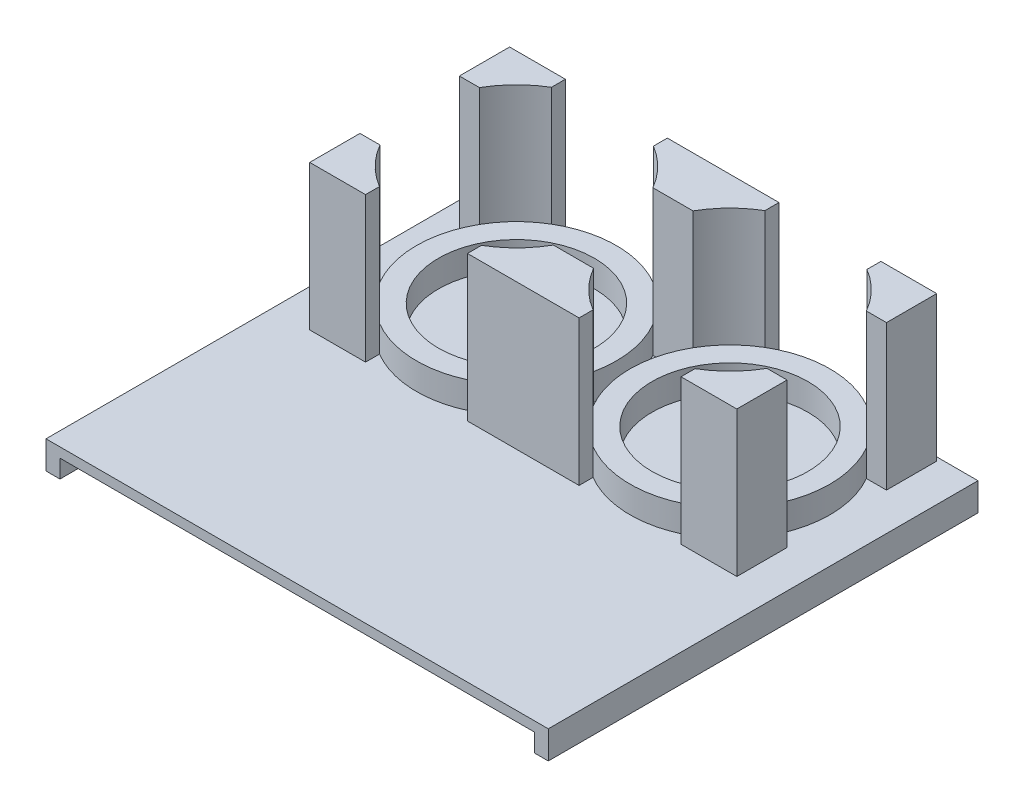
from build123d import *

# Parameters (mm, degrees)
SKETCH1_W           = 85
SKETCH1_H           = 77
BOSS_EXTRUDE1_DEPTH = 1.75
SKETCH3_R           = 17.907
SKETCH3_R_2         = 13.97
BOSS_EXTRUDE3_DEPTH = 4.7625
BOSS_EXTRUDE7_DEPTH = 26
SKETCH6_W           = 77
SKETCH6_H           = 5
BOSS_EXTRUDE8_DEPTH = 2.5


with BuildPart() as part:
    # Sketch1 → Boss-Extrude1 (new body)
    with BuildSketch(Plane(origin=(0, 0, 0), x_dir=(1, 0, 0), z_dir=(0, 1, 0))):
        Rectangle(SKETCH1_W, SKETCH1_H)
    extrude(amount=BOSS_EXTRUDE1_DEPTH)

    # Sketch3 → Boss-Extrude3 (add)
    with BuildSketch(Plane(origin=(0, 1.75, 0), x_dir=(1, 0, 0), z_dir=(0, 1, 0))):
        with Locations((19.133331774, 19.92813227)):
            Circle(SKETCH3_R)
        with Locations((19.133331774, 19.92813227)):
            Circle(SKETCH3_R_2, mode=Mode.SUBTRACT)
        with Locations((-19.133331774, 19.92813227)):
            Circle(SKETCH3_R)
        with Locations((-19.133331774, 19.92813227)):
            Circle(SKETCH3_R_2, mode=Mode.SUBTRACT)
    extrude(amount=BOSS_EXTRUDE3_DEPTH)

    # Sketch4 → Boss-Extrude7 (add)
    with BuildSketch(Plane(origin=(0, 1.75, 0), x_dir=(1, 0, 0), z_dir=(0, 1, 0))):
        with BuildLine():
            ThreePointArc((-34.668002675, 28.83513227), (-31.887785522, 32.497323119), (-28.266663548, 35.330823584))
            Line((-28.266663548, 35.330823584), (-28.266663548, 37.83513227))
            Line((-28.266663548, 37.83513227), (-38.266663548, 37.83513227))
            Line((-38.266663548, 37.83513227), (-38.266663548, 28.83513227))
            Line((-38.266663548, 28.83513227), (-34.668002675, 28.83513227))
        make_face()
        with BuildLine():
            ThreePointArc((-28.266663548, 4.525440956), (-31.887785522, 7.358941421), (-34.668002675, 11.02113227))
            Line((-34.668002675, 11.02113227), (-38.266663548, 11.02113227))
            Line((-38.266663548, 11.02113227), (-38.266663548, 2.02113227))
            Line((-38.266663548, 2.02113227), (-28.266663548, 2.02113227))
            Line((-28.266663548, 2.02113227), (-28.266663548, 4.525440956))
        make_face()
        with BuildLine():
            Line((0, 11.02113227), (-3.598660873, 11.02113227))
            ThreePointArc((-3.598660873, 11.02113227), (-6.378878026, 7.358941421), (-10, 4.525440956))
            Line((-10, 4.525440956), (-10, 2.02113227))
            Line((-10, 2.02113227), (0, 2.02113227))
            Line((0, 2.02113227), (0, 11.02113227))
        make_face()
        with BuildLine():
            ThreePointArc((10, 4.525440956), (6.378878026, 7.358941421), (3.598660873, 11.02113227))
            Line((3.598660873, 11.02113227), (0, 11.02113227))
            Line((0, 11.02113227), (0, 2.02113227))
            Line((0, 2.02113227), (10, 2.02113227))
            Line((10, 2.02113227), (10, 4.525440956))
        make_face()
        with BuildLine():
            Line((0, 28.83513227), (0, 37.83513227))
            Line((0, 37.83513227), (-10, 37.83513227))
            Line((-10, 37.83513227), (-10, 35.330823584))
            ThreePointArc((-10, 35.330823584), (-6.378878026, 32.497323119), (-3.598660873, 28.83513227))
            Line((-3.598660873, 28.83513227), (0, 28.83513227))
        make_face()
        with BuildLine():
            Line((10, 37.83513227), (0, 37.83513227))
            Line((0, 37.83513227), (0, 28.83513227))
            Line((0, 28.83513227), (3.598660873, 28.83513227))
            ThreePointArc((3.598660873, 28.83513227), (6.378878026, 32.497323119), (10, 35.330823584))
            Line((10, 35.330823584), (10, 37.83513227))
        make_face()
        with BuildLine():
            Line((28.266663548, 37.83513227), (28.266663548, 35.330823584))
            ThreePointArc((28.266663548, 35.330823584), (31.887785522, 32.497323119), (34.668002675, 28.83513227))
            Line((34.668002675, 28.83513227), (38.266663548, 28.83513227))
            Line((38.266663548, 28.83513227), (38.266663548, 37.83513227))
            Line((38.266663548, 37.83513227), (28.266663548, 37.83513227))
        make_face()
        with BuildLine():
            ThreePointArc((34.668002675, 11.02113227), (31.887785522, 7.358941421), (28.266663548, 4.525440956))
            Line((28.266663548, 4.525440956), (28.266663548, 2.02113227))
            Line((28.266663548, 2.02113227), (38.266663548, 2.02113227))
            Line((38.266663548, 2.02113227), (38.266663548, 11.02113227))
            Line((38.266663548, 11.02113227), (34.668002675, 11.02113227))
        make_face()
    extrude(amount=BOSS_EXTRUDE7_DEPTH)

    # Sketch6 → Boss-Extrude8 (add)
    with BuildSketch(Plane.ZY.offset(42.5)):
        with Locations((0, -0.75)):
            Rectangle(SKETCH6_W, SKETCH6_H)
    boss_extrude8 = extrude(amount=BOSS_EXTRUDE8_DEPTH)

    # Mirror1: Boss-Extrude8 across plane
    add(boss_extrude8.mirror(Plane(origin=(0, 0, 0), x_dir=(0, 0, 1), z_dir=(1, 0, 0))))


solid = part.part
